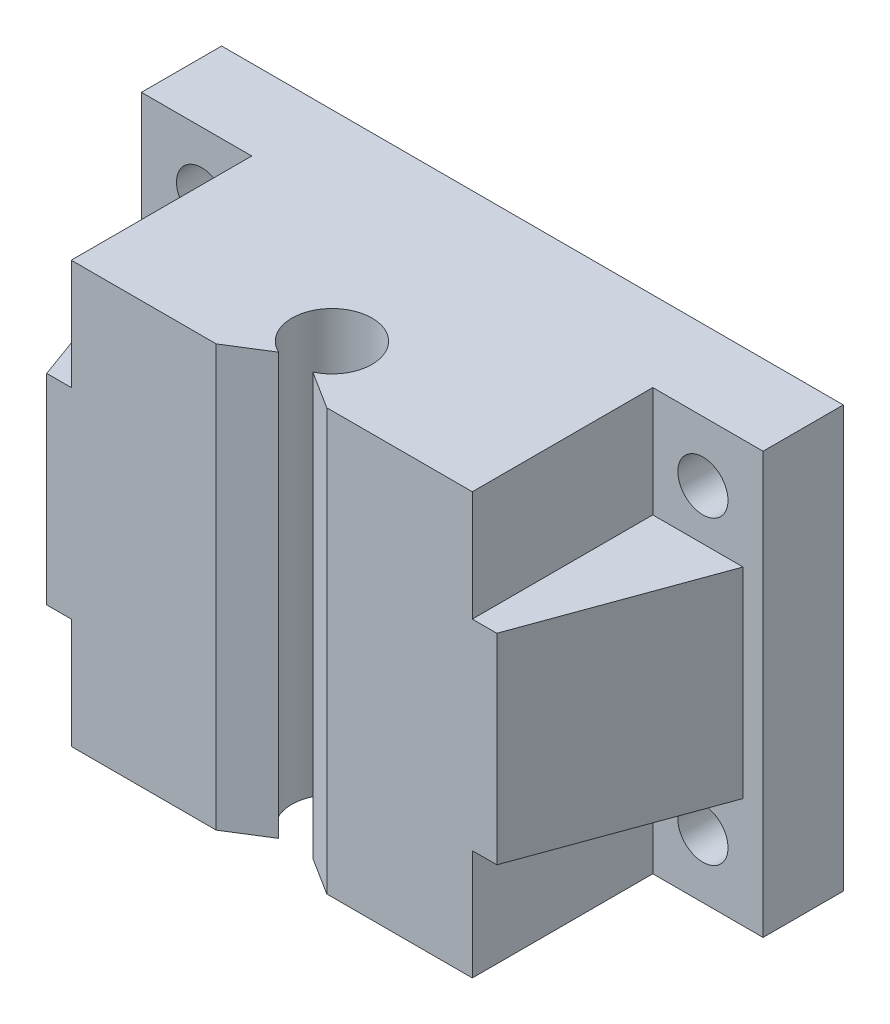
from build123d import *

# Parameters (mm, degrees)
EXTRUDE1_DEPTH        = 21
EXTRUDE1_DEPTH_BACK   = 21
EXTRUDE2_DEPTH        = 10
EXTRUDE2_DEPTH_BACK   = 10
CORTAR_EXTRUIR1_REACH = 47.585
CROQUIS1_R            = 2.5


with BuildPart() as part:
    # Sketch1 → Extrude1 (new, two sides: drawn at the far end of the back side and taken through both)
    with BuildSketch(Plane(origin=(0, 0, 0), x_dir=(1, 0, 0), z_dir=(0, 1, 0)).offset(-EXTRUDE1_DEPTH_BACK)):
        with BuildLine():
            Line((20, -22), (20, -4))
            Line((20, -4), (29, -4))
            Line((29, -4), (31, -4))
            Line((31, -4), (31, 4))
            Line((31, 4), (-31, 4))
            Line((-31, 4), (-31, -4))
            Line((-31, -4), (-29, -4))
            Line((-29, -4), (-20, -4))
            Line((-20, -4), (-20, -22))
            Line((-20, -22), (-5.546820257, -22))
            Line((-5.546820257, -22), (-1.724579107, -19.609131046))
            ThreePointArc((-1.724579107, -19.609131046), (0.008719361, -12.000009503), (1.708828096, -19.616615343))
            Line((1.708828096, -19.616615343), (5.482961188, -22))
            Line((5.482961188, -22), (20, -22))
        make_face()
    extrude(amount=EXTRUDE1_DEPTH + EXTRUDE1_DEPTH_BACK)

    # Sketch1_8 → Extrude2 (add, two sides: drawn at the far end of the back side and taken through both)
    with BuildSketch(Plane(origin=(0, 0, 0), x_dir=(1, 0, 0), z_dir=(0, 1, 0)).offset(-EXTRUDE2_DEPTH_BACK)):
        Polygon((29, -4), (20, -4), (20, -22), (22.448535783, -22), align=None)
        Polygon((-20, -4), (-29, -4), (-22.448535783, -22), (-20, -22), align=None)
    extrude(amount=EXTRUDE2_DEPTH + EXTRUDE2_DEPTH_BACK)

    # Croquis1 → Cortar-Extruir1 (cut, up to next)
    with BuildSketch(Plane(origin=(0, 0, -4), x_dir=(-1, 0, 0), z_dir=(0, 0, -1)), mode=Mode.PRIVATE) as cortar_extruir1_sk1:
        with Locations((-25, 15)):
            Circle(CROQUIS1_R)
    cortar_extruir1_tool1 = extrude(cortar_extruir1_sk1.sketch, amount=-CORTAR_EXTRUIR1_REACH, mode=Mode.PRIVATE) & part.part
    # Croquis1 → Cortar-Extruir1 (cut, up to next)
    with BuildSketch(Plane(origin=(0, 0, -4), x_dir=(-1, 0, 0), z_dir=(0, 0, -1)), mode=Mode.PRIVATE) as cortar_extruir1_sk2:
        with Locations((25, 15)):
            Circle(CROQUIS1_R)
    cortar_extruir1_tool2 = extrude(cortar_extruir1_sk2.sketch, amount=-CORTAR_EXTRUIR1_REACH, mode=Mode.PRIVATE) & part.part
    # Croquis1 → Cortar-Extruir1 (cut, up to next)
    with BuildSketch(Plane(origin=(0, 0, -4), x_dir=(-1, 0, 0), z_dir=(0, 0, -1)), mode=Mode.PRIVATE) as cortar_extruir1_sk3:
        with Locations((-25, -15)):
            Circle(CROQUIS1_R)
    cortar_extruir1_tool3 = extrude(cortar_extruir1_sk3.sketch, amount=-CORTAR_EXTRUIR1_REACH, mode=Mode.PRIVATE) & part.part
    # Croquis1 → Cortar-Extruir1 (cut, up to next)
    with BuildSketch(Plane(origin=(0, 0, -4), x_dir=(-1, 0, 0), z_dir=(0, 0, -1)), mode=Mode.PRIVATE) as cortar_extruir1_sk4:
        with Locations((25, -15)):
            Circle(CROQUIS1_R)
    cortar_extruir1_tool4 = extrude(cortar_extruir1_sk4.sketch, amount=-CORTAR_EXTRUIR1_REACH, mode=Mode.PRIVATE) & part.part
    add(cortar_extruir1_tool1.solids().sort_by_distance((25, 15, -4))[0], mode=Mode.SUBTRACT)
    add(cortar_extruir1_tool2.solids().sort_by_distance((-25, 15, -4))[0], mode=Mode.SUBTRACT)
    add(cortar_extruir1_tool3.solids().sort_by_distance((25, -15, -4))[0], mode=Mode.SUBTRACT)
    add(cortar_extruir1_tool4.solids().sort_by_distance((-25, -15, -4))[0], mode=Mode.SUBTRACT)


solid = part.part
